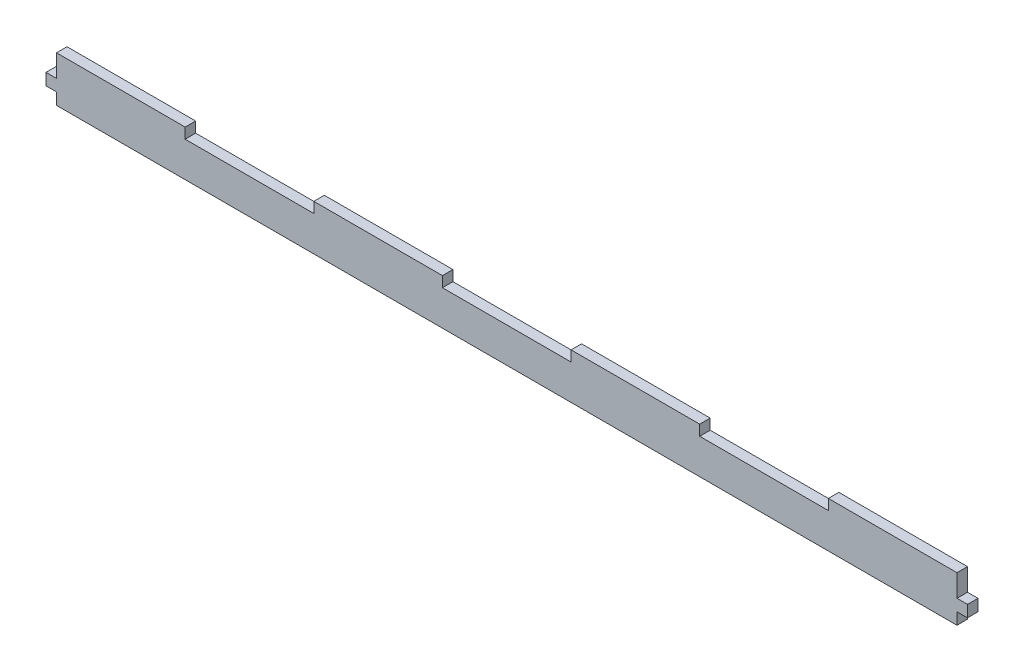
from build123d import *

# Parameters (mm, degrees)
SKETCH1_W               = 466
SKETCH1_H               = 126.5
BOSS_EXTRUDE1_DEPTH     = 6
SKETCH2_W               = 514
SKETCH2_H               = 6
BOSS_EXTRUDE2_DEPTH     = 20
CUT_EXTRUDE1_DEPTH      = 274.752739712
CUT_EXTRUDE1_DEPTH_BACK = 274.752739712
SKETCH1_2_W             = 466
SKETCH1_2_H             = 126.5
SKETCH2_4_W             = 73.428571429
SKETCH2_4_H             = 6
BOSS_EXTRUDE3_DEPTH     = 6
SKETCH4_W               = 6
SKETCH4_H               = 6.666666666
BOSS_EXTRUDE4_DEPTH     = 6


with BuildPart() as part:
    # Sketch1 → Boss-Extrude1 (new body)
    with BuildSketch(Plane(origin=(0, 0, 0), x_dir=(1, 0, 0), z_dir=(0, 1, 0))):
        Rectangle(SKETCH1_W, SKETCH1_H)
    extrude(amount=BOSS_EXTRUDE1_DEPTH)

    # Sketch1_2 → Cut-Extrude1 (cut, two sides: drawn at the far end of the back side and taken through both)
    with BuildSketch(Plane(origin=(0, 0, 0), x_dir=(1, 0, 0), z_dir=(0, 1, 0)).offset(-CUT_EXTRUDE1_DEPTH_BACK)):
        Rectangle(SKETCH1_2_W, SKETCH1_2_H)
    extrude(amount=CUT_EXTRUDE1_DEPTH + CUT_EXTRUDE1_DEPTH_BACK, mode=Mode.SUBTRACT)


with BuildPart() as body_2:
    # Sketch2 → Boss-Extrude2 (new body)
    with BuildSketch(Plane(origin=(0, 6, 0), x_dir=(1, 0, 0), z_dir=(0, 1, 0))):
        with Locations((0, 90.25)):
            Rectangle(SKETCH2_W, SKETCH2_H)
    extrude(amount=-BOSS_EXTRUDE2_DEPTH)

    # Sketch2_4 → Boss-Extrude3 (add)
    with BuildSketch(Plane(origin=(0, 6, 0), x_dir=(1, 0, 0), z_dir=(0, 1, 0))):
        with Locations((220.285714286, 90.25)):
            Rectangle(SKETCH2_4_W, SKETCH2_4_H)
        with Locations((73.428571428, 90.25)):
            Rectangle(SKETCH2_4_W, SKETCH2_4_H)
        with Locations((-73.428571428, 90.25)):
            Rectangle(SKETCH2_4_W, SKETCH2_4_H)
        with Locations((-220.285714286, 90.25)):
            Rectangle(SKETCH2_4_W, SKETCH2_4_H)
    extrude(amount=BOSS_EXTRUDE3_DEPTH)

    # Sketch4 → Boss-Extrude4 (add)
    with BuildSketch(Plane.ZY.offset(257)):
        with Locations((-90.25, -4)):
            Rectangle(SKETCH4_W, SKETCH4_H)
    boss_extrude4 = extrude(amount=BOSS_EXTRUDE4_DEPTH)

    # Mirror2: Boss-Extrude4 across plane
    add(boss_extrude4.mirror(Plane(origin=(0, 0, 0), x_dir=(0, 0, 1), z_dir=(1, 0, 0))))


solid = body_2.part
